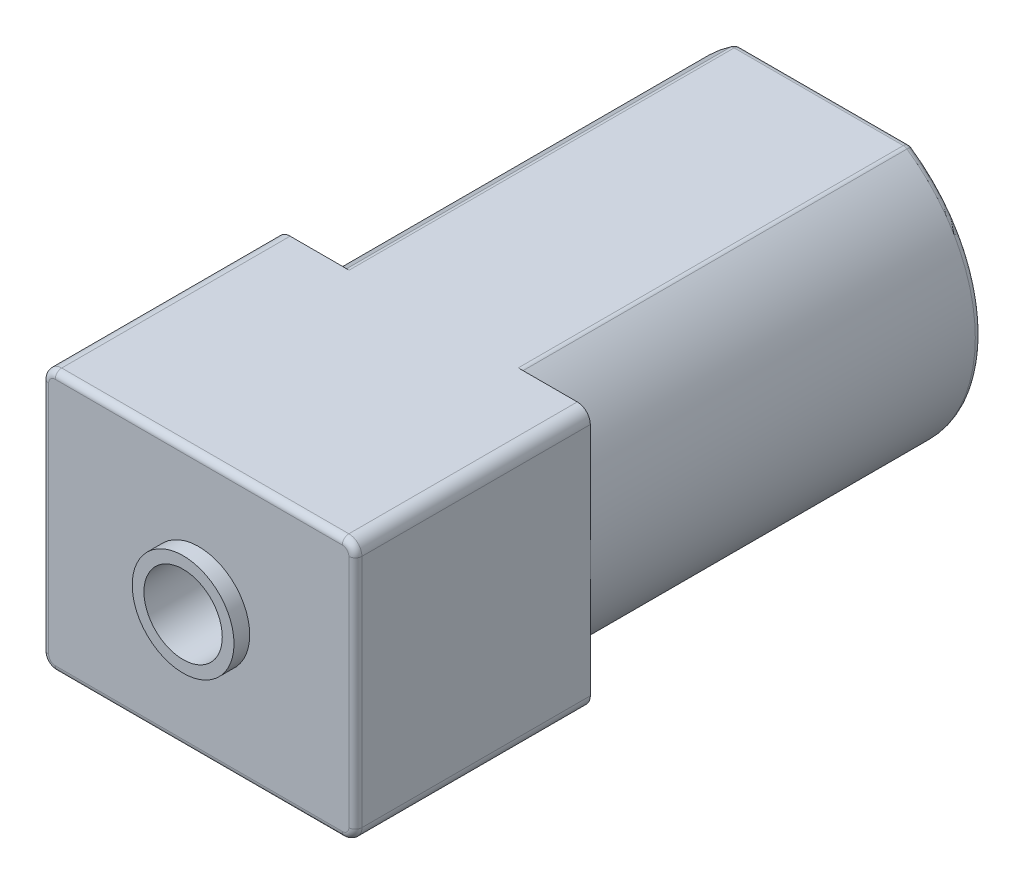
from build123d import *
from build123d.topology import SkipClean

# Parameters (mm, degrees)
SKETCH_1_R           = 6
EXTRUDE_1_DEPTH      = 15
SKETCH_2_OUTSIDE_W   = 18.53
SKETCH_2_OUTSIDE_H   = 18.53
SKETCH_2_OUTSIDE_W_2 = 12
SKETCH_2_OUTSIDE_H_2 = 10
CUT_EXTRUDE_3_DEPTH  = 15
SKETCH_2_3_W         = 12
SKETCH_2_3_H         = 10
EXTRUDE_2_DEPTH      = 9
FILLET_1_R           = 0.5
SKETCH_4_R           = 2.5
EXTRUDE_3_DEPTH      = 2
SKETCH_5_R           = 1.5
CUT_EXTRUDE_4_DEPTH  = 28.147743921
FILLET_2_R           = 0.25
FILLET_3_R           = 0.25
SKETCH_6_R           = 1.95
SKETCH_6_R_2         = 1.5
EXTRUDE_4_DEPTH      = 0.6


with BuildPart() as part:
    # Эскиз1 → Бобышка-Вытянуть1 (new body)
    with BuildSketch(Plane.XY):
        Circle(SKETCH_1_R)
    extrude(amount=EXTRUDE_1_DEPTH)

    # Эскиз2 outside → Вырез-Вытянуть3 (cut)
    with BuildSketch(Plane.XY.offset(15)):
        Rectangle(SKETCH_2_OUTSIDE_W, SKETCH_2_OUTSIDE_H)
        Rectangle(SKETCH_2_OUTSIDE_W_2, SKETCH_2_OUTSIDE_H_2, mode=Mode.SUBTRACT)
    extrude(amount=-CUT_EXTRUDE_3_DEPTH, mode=Mode.SUBTRACT)

    # Эскиз2<3> → Бобышка-Вытянуть2 (add)
    with BuildSketch(Plane.XY.offset(15)):
        Rectangle(SKETCH_2_3_W, SKETCH_2_3_H)
    extrude(amount=EXTRUDE_2_DEPTH)

    # Скругление1
    fillet_1_edges = [part.edges().sort_by_distance(p)[0] for p in [
        (6, 5, 19.5),
        (-6, 5, 19.5),
        (-6, -5, 19.5),
        (6, -5, 19.5),
    ]]
    fillet(fillet_1_edges, radius=FILLET_1_R)

    # Эскиз4 → Бобышка-Вытянуть3 (add)
    with BuildSketch(Plane(origin=(0, 0, 0), x_dir=(-1, 0, 0), z_dir=(0, 0, -1))):
        Circle(SKETCH_4_R)
    extrude(amount=EXTRUDE_3_DEPTH)

    # Эскиз5 → Вырез-Вытянуть4 (cut, through all)
    with BuildSketch(Plane(origin=(0, 0, -2), x_dir=(-1, 0, 0), z_dir=(0, 0, -1))):
        Circle(SKETCH_5_R)
    extrude(amount=-CUT_EXTRUDE_4_DEPTH, mode=Mode.SUBTRACT)

    # Скругление2
    fillet_2_edges = [part.edges().sort_by_distance(p)[0] for p in [
        (5.853553391, 4.853553391, 24),
        (6, 0, 24),
        (5.853553391, -4.853553391, 24),
        (0, -5, 24),
        (-5.853553391, -4.853553391, 24),
        (-6, 0, 24),
        (-5.853553391, 4.853553391, 24),
        (0, 5, 24),
    ]]
    fillet(fillet_2_edges, radius=FILLET_2_R)

    # Скругление3
    fillet_3_edges = [part.edges().sort_by_distance(p)[0] for p in [
        (2.5, 0, -2),
        (2.5, 0, 0),
        (3.31662479, -5, 7.5),
        (-3.31662479, -5, 7.5),
        (-3.31662479, 5, 7.5),
        (3.31662479, 5, 7.5),
        (6, 0, 0),
        (-6, 0, 0),
        (0, -5, 0),
        (0, 5, 0),
    ]]
    fillet(fillet_3_edges, radius=FILLET_3_R)

    # Эскиз6 → Бобышка-Вытянуть4 (add)
    with SkipClean():  # the faces are left unmerged after this step: merging them gives an invalid solid
        with BuildSketch(Plane.XY.offset(24)):
            Circle(SKETCH_6_R)
            Circle(SKETCH_6_R_2, mode=Mode.SUBTRACT)
        extrude(amount=EXTRUDE_4_DEPTH)


solid = part.part
